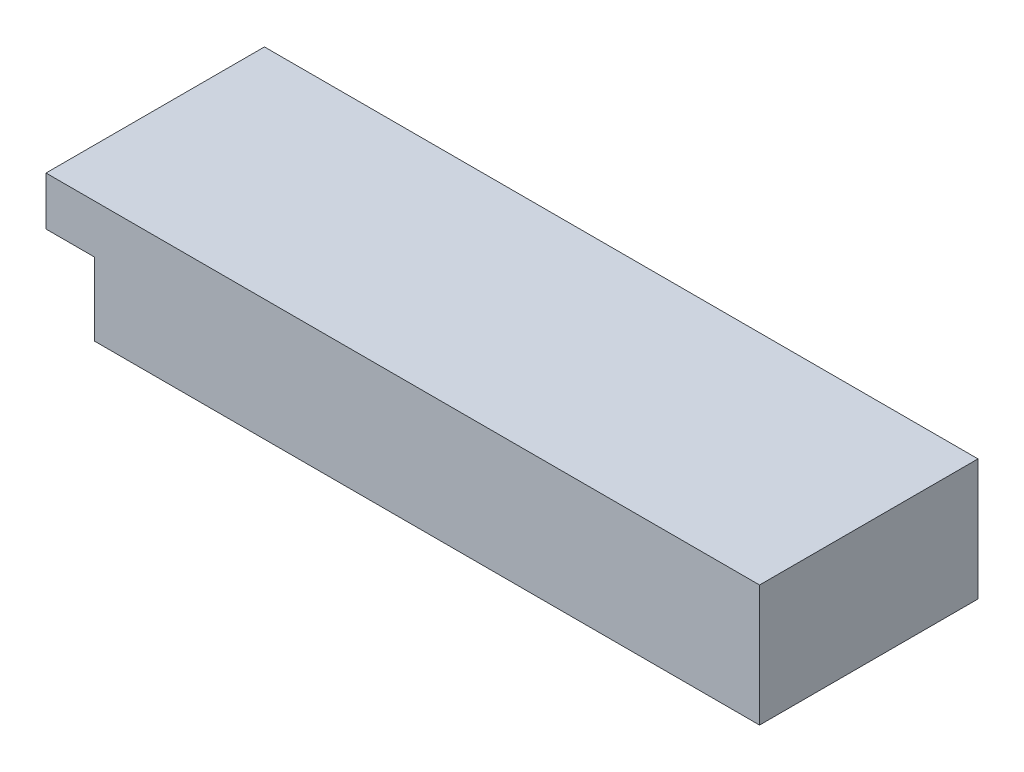
from build123d import *

# Parameters (mm, degrees)
SKETCH1_W           = 137
SKETCH1_H           = 45
BOSS_EXTRUDE1_DEPTH = 25
SKETCH2_W           = 45
SKETCH2_H           = 10
BOSS_EXTRUDE2_DEPTH = 10


with BuildPart() as part:
    # Sketch1 → Boss-Extrude1 (new body)
    with BuildSketch(Plane(origin=(0, 0, 0), x_dir=(1, 0, 0), z_dir=(0, 1, 0))):
        with Locations((68.5, 22.5)):
            Rectangle(SKETCH1_W, SKETCH1_H)
    extrude(amount=BOSS_EXTRUDE1_DEPTH)

    # Sketch2 → Boss-Extrude2 (add)
    with BuildSketch(Plane.ZY):
        with Locations((-22.5, 20)):
            Rectangle(SKETCH2_W, SKETCH2_H)
    extrude(amount=BOSS_EXTRUDE2_DEPTH)


solid = part.part
